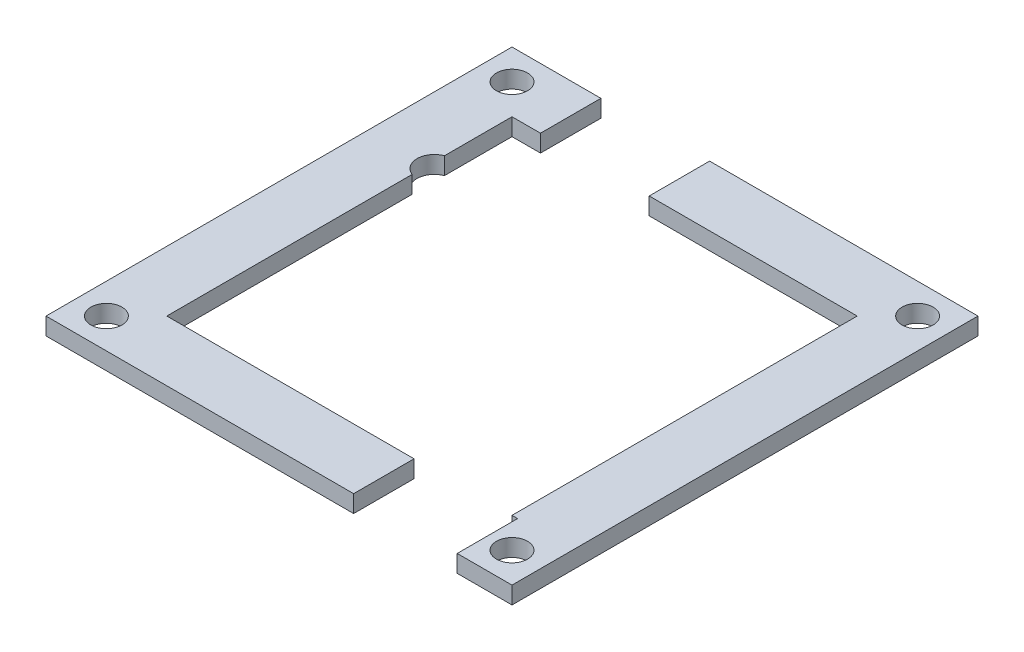
from build123d import *

# Parameters (mm, degrees)
SKETCH_3_R        = 1.8
EXTRUDE_2_DEPTH   = 2
EXTRUDE_2_2_DEPTH = 2


with BuildPart() as part:
    # 草图3 → 凸台-拉伸2 (new body)
    with BuildSketch(Plane(origin=(0, 0, 0), x_dir=(1, 0, 0), z_dir=(0, 1, 0))):
        with BuildLine():
            Line((-27, -27), (8.65, -27))
            Line((8.65, -27), (8.65, -20))
            Line((8.65, -20), (-20, -20))
            Line((-20, -20), (-20, 8.4265006))
            ThreePointArc((-20, 8.4265006), (-21.3, 10.3), (-20, 12.1734994))
            Line((-20, 12.1734994), (-20, 20))
            Line((-20, 20), (-16.7, 20))
            Line((-16.7, 20), (-16.7, 27))
            Line((-16.7, 27), (-27, 27))
            Line((-27, 27), (-27, -27))
        make_face()
        with Locations((-23.5, -23.5)):
            Circle(SKETCH_3_R, mode=Mode.SUBTRACT)
        with Locations((-23.5, 23.5)):
            Circle(SKETCH_3_R, mode=Mode.SUBTRACT)
    extrude(amount=EXTRUDE_2_DEPTH)


with BuildPart() as body_2:
    # 草图3 → Extrude 2 2 (new body)
    with BuildSketch(Plane(origin=(0, 0, 0), x_dir=(1, 0, 0), z_dir=(0, 1, 0))):
        Polygon((20, 20), (20, -20), (20.65, -20), (20.65, -27), (27, -27), (27, 27), (-4.1, 27), (-4.1, 20), align=None)
        with Locations((23.5, -23.5)):
            Circle(SKETCH_3_R, mode=Mode.SUBTRACT)
        with Locations((23.5, 23.5)):
            Circle(SKETCH_3_R, mode=Mode.SUBTRACT)
    extrude(amount=EXTRUDE_2_2_DEPTH)


solid = Compound([part.part, body_2.part])
